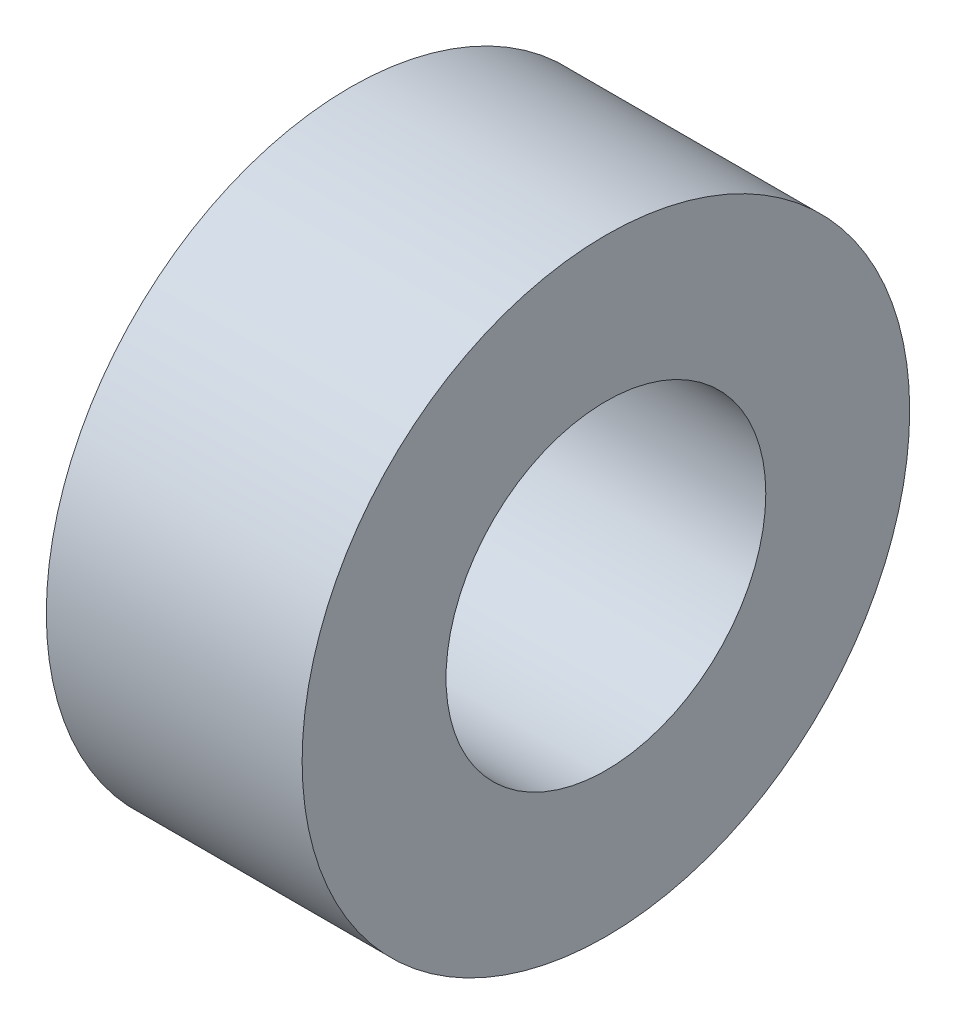
from build123d import *

# Parameters (mm, degrees)
SKETCH1_R           = 9.5
SKETCH1_R_2         = 5
BOSS_EXTRUDE1_DEPTH = 8


with BuildPart() as part:
    # Sketch1 → Boss-Extrude1 (new body)
    with BuildSketch(Plane(origin=(0, 0, 0), x_dir=(0, 0, -1), z_dir=(1, 0, 0))):
        Circle(SKETCH1_R)
        Circle(SKETCH1_R_2, mode=Mode.SUBTRACT)
    extrude(amount=BOSS_EXTRUDE1_DEPTH)


solid = part.part
